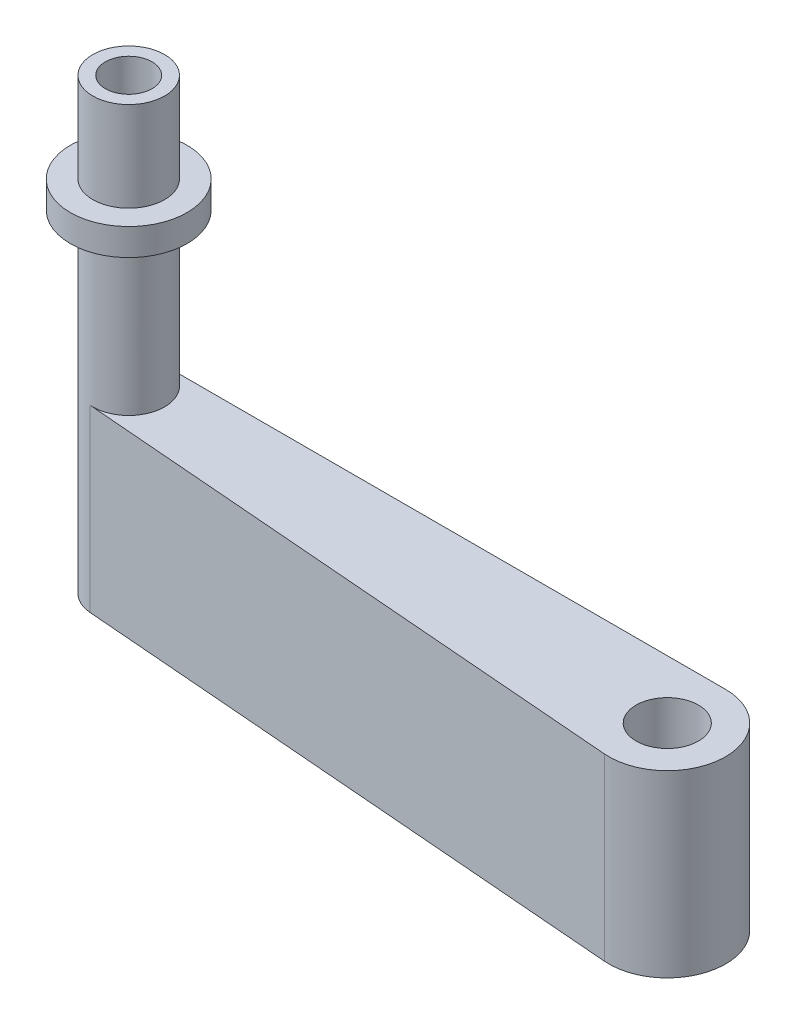
from build123d import *

# Parameters (mm, degrees)
SALIENTE_EXTRUIR1_DEPTH = 10
CROQUIS2_R              = 3.475
CORTAR_EXTRUIR1_DEPTH   = 21
CROQUIS3_R              = 4
SALIENTE_EXTRUIR2_DEPTH = 30
CROQUIS4_R              = 2.6
CORTAR_EXTRUIR2_DEPTH   = 10
SALIENTE_EXTRUIR3_START = -13
CROQUIS6_R              = 6.5
CROQUIS6_R_2            = 4
SALIENTE_EXTRUIR3_DEPTH = 3


with BuildPart() as part:
    # Croquis1 → Saliente-Extruir1 (new body, symmetric)
    with BuildSketch(Plane(origin=(0, 0, 0), x_dir=(1, 0, 0), z_dir=(0, 1, 0))):
        with BuildLine():
            Line((-62.5, 6.5), (0, 6.5))
            ThreePointArc((0, 6.5), (6.494806232, -0.259792249), (-0.519169329, -6.479233227))
            Line((-0.519169329, -6.479233227), (-62.819488818, -1.487220447))
            ThreePointArc((-62.819488818, -1.487220447), (-66.496803835, 2.659872153), (-62.5, 6.5))
        make_face()
    extrude(amount=SALIENTE_EXTRUIR1_DEPTH, both=True)

    # Croquis2 → Cortar-Extruir1 (cut, through all)
    with BuildSketch(Plane(origin=(0, 10, 0), x_dir=(1, 0, 0), z_dir=(0, 1, 0))):
        Circle(CROQUIS2_R)
    extrude(amount=-CORTAR_EXTRUIR1_DEPTH, mode=Mode.SUBTRACT)

    # Croquis3 → Saliente-Extruir2 (add)
    with BuildSketch(Plane(origin=(0, 10, 0), x_dir=(1, 0, 0), z_dir=(0, 1, 0))):
        with Locations((-62.5, 2.5)):
            Circle(CROQUIS3_R)
    extrude(amount=SALIENTE_EXTRUIR2_DEPTH)

    # Croquis4 → Cortar-Extruir2 (cut)
    with BuildSketch(Plane(origin=(0, 40, 0), x_dir=(1, 0, 0), z_dir=(0, 1, 0))):
        with Locations((-62.5, 2.5)):
            Circle(CROQUIS4_R)
    extrude(amount=-CORTAR_EXTRUIR2_DEPTH, mode=Mode.SUBTRACT)


with BuildPart() as body_2:
    # Croquis6 → Saliente-Extruir3 (new body)
    with BuildSketch(Plane(origin=(0, 40, 0), x_dir=(1, 0, 0), z_dir=(0, 1, 0)).offset(SALIENTE_EXTRUIR3_START)):
        with Locations((-62.5, 2.5)):
            Circle(CROQUIS6_R)
        with Locations((-62.5, 2.5)):
            Circle(CROQUIS6_R_2, mode=Mode.SUBTRACT)
    extrude(amount=SALIENTE_EXTRUIR3_DEPTH)


solid = Compound([part.part, body_2.part])
